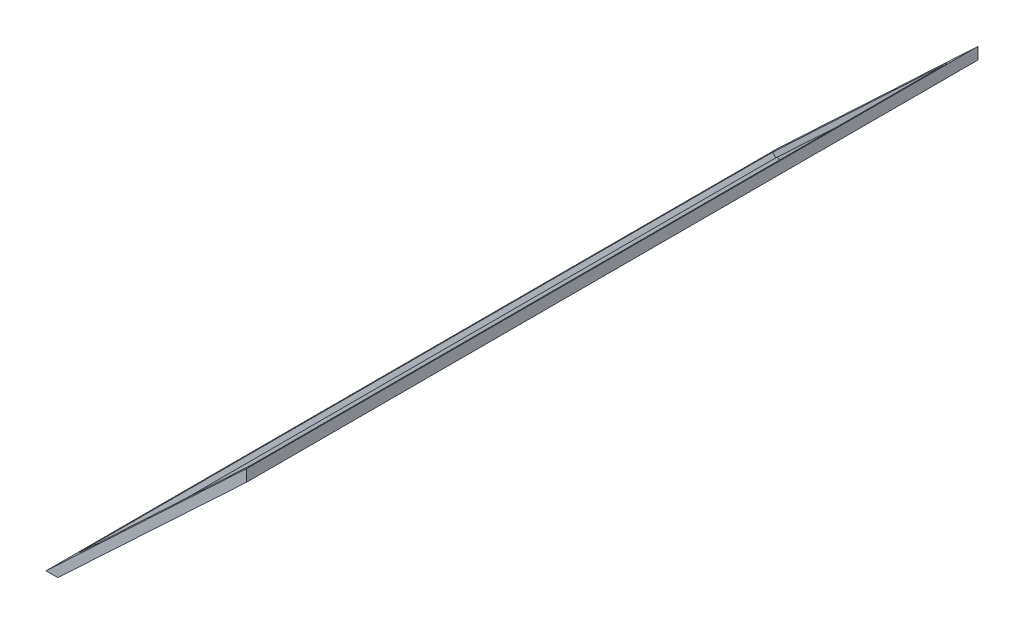
from build123d import *

# Parameters (mm, degrees)
SALIENTE_EXTRUIR1_DEPTH = 620
CROQUIS2_W              = 203.452350599
CROQUIS2_H              = 590
CORTAR_EXTRUIR1_DEPTH   = 117.511998831
CROQUIS3_W              = 213.451905324
CROQUIS3_H              = 600
CORTAR_EXTRUIR2_DEPTH   = 3


with BuildPart() as part:
    # Croquis1 → Saliente-Extruir1 (new body)
    with BuildSketch(Plane.XY):
        Polygon((0, 0), (160, 150), (160, 160), (-10, 0), align=None)
    extrude(amount=SALIENTE_EXTRUIR1_DEPTH)

    # Croquis2 → Cortar-Extruir1 (cut, through all)
    with BuildSketch(Plane(origin=(-4.697247706, 4.990825688, 0), x_dir=(0.728199993, 0.685364699, 0), z_dir=(-0.685364699, 0.728199993, 0))):
        with Locations((109.444175373, -310)):
            Rectangle(CROQUIS2_W, CROQUIS2_H)
    extrude(amount=-CORTAR_EXTRUIR1_DEPTH, mode=Mode.SUBTRACT)

    # Croquis3 → Cortar-Extruir2 (cut)
    with BuildSketch(Plane(origin=(0, 0, 0), x_dir=(0.729537204, 0.683941129, 0), z_dir=(0.683941129, -0.729537204, 0))):
        with Locations((109.430580621, 310)):
            Rectangle(CROQUIS3_W, CROQUIS3_H)
    extrude(amount=-CORTAR_EXTRUIR2_DEPTH, mode=Mode.SUBTRACT)


solid = part.part
